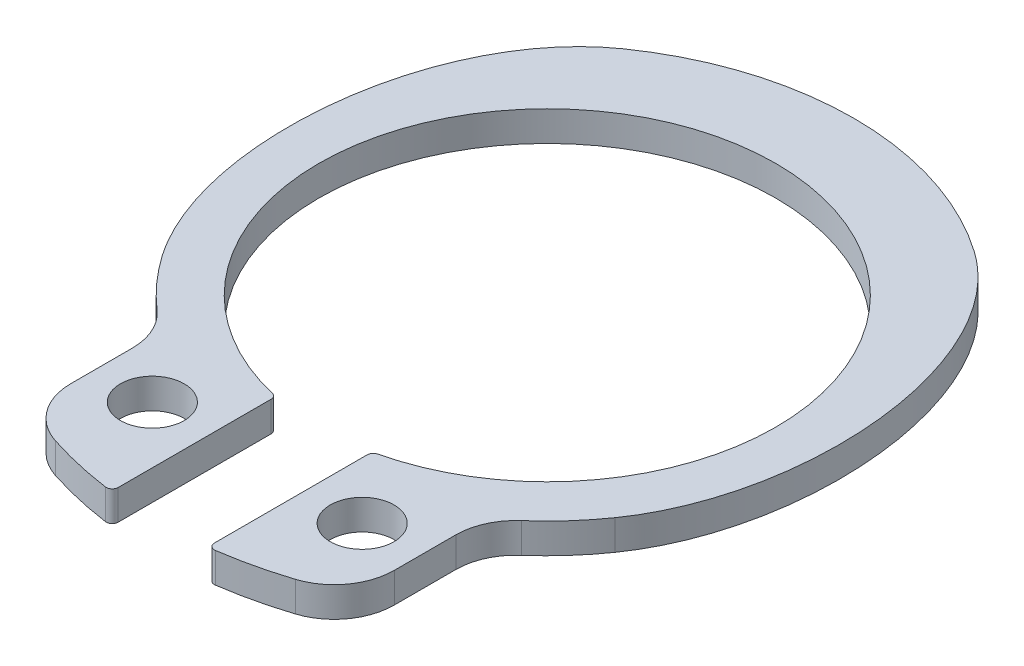
from build123d import *

# Parameters (mm, degrees)
SCHIZZO1_R                   = 0.265127494
ESTRUSIONE_ESTRUSIONE1_DEPTH = 0.25


with BuildPart() as part:
    # Schizzo1 → Estrusione-Estrusione1 (new body)
    with BuildSketch(Plane(origin=(0, 0.125, 0), x_dir=(1, 0, 0), z_dir=(0, 1, 0))):
        with BuildLine():
            Line((-0.4, -3.168201382), (-0.4, -1.897366596))
            ThreePointArc((-0.4, -1.897366596), (-0.410776773, -1.866357912), (-0.438461538, -1.848716171))
            ThreePointArc((-0.438461538, -1.848716171), (0, 1.9), (0.438461538, -1.848716171))
            ThreePointArc((0.438461538, -1.848716171), (0.410776773, -1.866357912), (0.4, -1.897366596))
            Line((0.4, -1.897366596), (0.4, -3.168201382))
            ThreePointArc((0.4, -3.168201382), (0.417224723, -3.205960901), (0.45703125, -3.217704529))
            ThreePointArc((0.45703125, -3.217704529), (0.730509561, -3.166836873), (0.998636364, -3.092769861))
            ThreePointArc((0.998636364, -3.092769861), (1.249238903, -2.911222446), (1.345, -2.616959113))
            Line((1.345, -2.616959113), (1.345, -2.106175444))
            ThreePointArc((1.345, -2.106175444), (1.38962535, -1.899695594), (1.515535714, -1.730072686))
            ThreePointArc((1.515535714, -1.730072686), (1.712160635, -1.535742804), (1.884049702, -1.319225804))
            add(Edge.make_bspline(
                [(1.884049702, -1.319225804), (2.019028975, -1.126455424), (2.115110162, -0.904375316), (2.179460327, -0.678015249), (2.270153104, -0.358991622), (2.302501228, -0.019899245), (2.285387374, 0.311323295), (2.26784312, 0.650875841), (2.197551078, 0.994363091), (2.063917418, 1.307006302), (1.984645052, 1.492468311), (1.88078204, 1.670669807), (1.750288587, 1.824460975), (1.666028558, 1.923764412), (1.569301455, 2.014138493), (1.462619913, 2.088837713)],
                knots=[0, 0, 0, 0, 0.000705988, 0.000705988, 0.000705988, 0.001703524, 0.001703524, 0.001703524, 0.002727653, 0.002727653, 0.002727653, 0.003330782, 0.003330782, 0.003330782, 0.0037183, 0.0037183, 0.0037183, 0.0037183], degree=3))
            ThreePointArc((1.462619913, 2.088837713), (0, 2.55), (-1.462619913, 2.088837713))
            add(Edge.make_bspline(
                [(-1.462619913, 2.088837713), (-1.615530694, 1.981768431), (-1.747869333, 1.842005153), (-1.854500953, 1.688788849), (-1.995460269, 1.486247938), (-2.097780092, 1.254601869), (-2.167328588, 1.017841745), (-2.264449586, 0.68721807), (-2.302378714, 0.335122463), (-2.286139342, -0.009087917), (-2.269658272, -0.358421336), (-2.196778774, -0.714119474), (-2.049077035, -1.031120515), (-2.002334914, -1.131439586), (-1.947529721, -1.228566942), (-1.884049702, -1.319225804)],
                knots=[0, 0, 0, 0, 0.000560009, 0.000560009, 0.000560009, 0.001300888, 0.001300888, 0.001300888, 0.002338839, 0.002338839, 0.002338839, 0.003395612, 0.003395612, 0.003395612, 0.003723988, 0.003723988, 0.003723988, 0.003723988], degree=3))
            ThreePointArc((-1.884049702, -1.319225804), (-1.712160635, -1.535742804), (-1.515535714, -1.730072686))
            ThreePointArc((-1.515535714, -1.730072686), (-1.38962535, -1.899695594), (-1.345, -2.106175444))
            Line((-1.345, -2.106175444), (-1.345, -2.616959113))
            ThreePointArc((-1.345, -2.616959113), (-1.249238903, -2.911222446), (-0.998636364, -3.092769861))
            ThreePointArc((-0.998636364, -3.092769861), (-0.730509561, -3.166836873), (-0.45703125, -3.217704529))
            ThreePointArc((-0.45703125, -3.217704529), (-0.417224723, -3.205960901), (-0.4, -3.168201382))
        make_face()
        with Locations((0.8725, -2.412182168)):
            Circle(SCHIZZO1_R, mode=Mode.SUBTRACT)
        with Locations((-0.8725, -2.412182168)):
            Circle(SCHIZZO1_R, mode=Mode.SUBTRACT)
    extrude(amount=-ESTRUSIONE_ESTRUSIONE1_DEPTH)


solid = part.part
